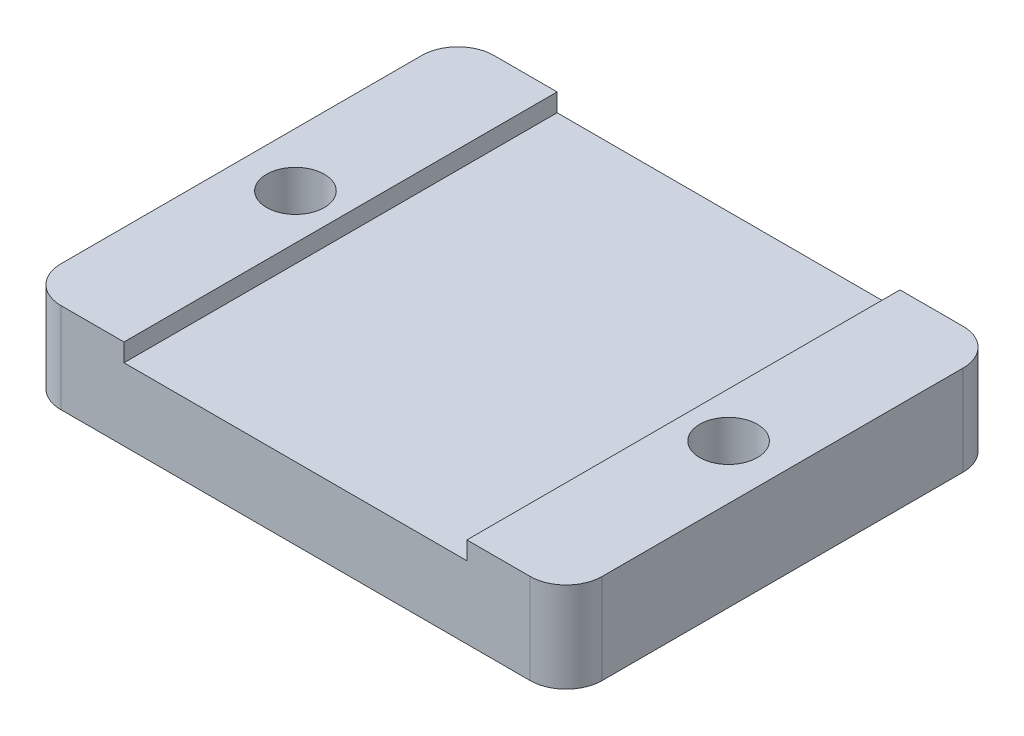
from build123d import *

# Parameters (mm, degrees)
SKETCH_1_W      = 30
SKETCH_1_H      = 24
SKETCH_1_R      = 1.6
EXTRUDE_1_DEPTH = 4
SKETCH_2_W      = 5.5
SKETCH_2_H      = 24
SKETCH_2_R      = 1.6
EXTRUDE_2_DEPTH = 1
FILLET_1_R      = 2


with BuildPart() as part:
    # 草图1 → 凸台-拉伸1 (new body)
    with BuildSketch(Plane(origin=(0, 0, 0), x_dir=(1, 0, 0), z_dir=(0, 1, 0))):
        Rectangle(SKETCH_1_W, SKETCH_1_H)
        with Locations((-12, 0)):
            Circle(SKETCH_1_R, mode=Mode.SUBTRACT)
        with Locations((12, 0)):
            Circle(SKETCH_1_R, mode=Mode.SUBTRACT)
    extrude(amount=EXTRUDE_1_DEPTH)

    # 草图2 → 凸台-拉伸2 (add)
    with BuildSketch(Plane(origin=(0, 4, 0), x_dir=(1, 0, 0), z_dir=(0, 1, 0))):
        with Locations((-12.25, 0)):
            Rectangle(SKETCH_2_W, SKETCH_2_H)
        with Locations((-12, 0)):
            Circle(SKETCH_2_R, mode=Mode.SUBTRACT)
        with Locations((12.25, 0)):
            Rectangle(SKETCH_2_W, SKETCH_2_H)
        with Locations((12, 0)):
            Circle(SKETCH_2_R, mode=Mode.SUBTRACT)
    extrude(amount=EXTRUDE_2_DEPTH)

    # 圆角1
    fillet_1_edges = [part.edges().sort_by_distance(p)[0] for p in [
        (15, 2.5, 12),
        (-15, 2.5, 12),
        (-15, 2.5, -12),
        (15, 2.5, -12),
    ]]
    fillet(fillet_1_edges, radius=FILLET_1_R)


solid = part.part
